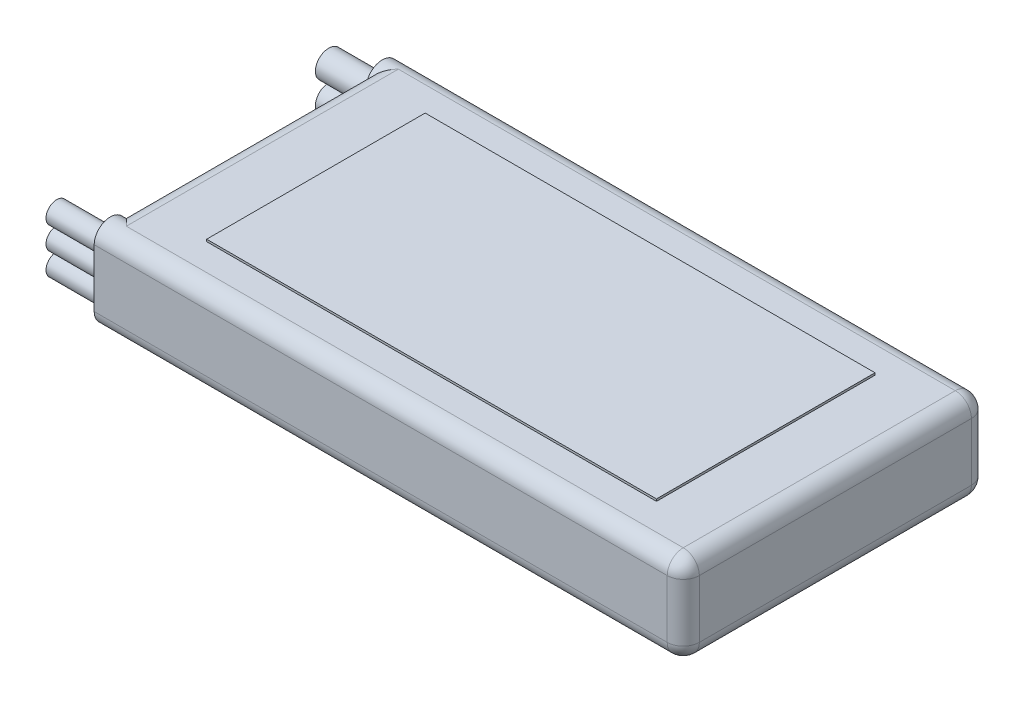
from build123d import *

# Parameters (mm, degrees)
SKETCH1_W       = 69.85
SKETCH1_H       = 36.068
BATTERY_DEPTH   = 10.668
FILLET_2_R      = 1.905
WIRE_BOSS_DEPTH = 5.08
SKETCH3_R       = 1.27
SKETCH3_R_2     = 1.5875
WIRES_2_DEPTH   = 6.35
SKETCH4_W       = 53.34
SKETCH4_H       = 25.908
LABEL_DEPTH     = 0.254


with BuildPart() as part:
    # Sketch1 → Battery (new body)
    with BuildSketch(Plane(origin=(0, 0, 0), x_dir=(1, 0, 0), z_dir=(0, 1, 0))):
        with Locations((8.399917755, 5.125761329)):
            Rectangle(SKETCH1_W, SKETCH1_H)
    extrude(amount=BATTERY_DEPTH)

    # Fillet 2
    fillet_2_edges = [part.edges().sort_by_distance(p)[0] for p in [
        (43.324917755, 10.668, -5.125761329),
        (8.399917755, 10.668, -23.159761329),
        (-26.525082245, 10.668, -5.125761329),
        (8.399917755, 0, -23.159761329),
        (43.324917755, 0, -5.125761329),
        (8.399917755, 0, 12.908238671),
        (-26.525082245, 0, -5.125761329),
        (8.399917755, 10.668, 12.908238671),
        (-26.525082245, 5.334, -23.159761329),
        (43.324917755, 5.334, -23.159761329),
        (43.324917755, 5.334, 12.908238671),
        (-26.525082245, 5.334, 12.908238671),
    ]]
    fillet(fillet_2_edges, radius=FILLET_2_R)

    # Sketch2 → Wire Boss (add)
    with BuildSketch(Plane.ZY.offset(26.525082245)):
        with BuildLine():
            Line((12.908238671, 8.763), (12.908238671, 1.905))
            ThreePointArc((12.908238671, 1.905), (11.003238671, 0), (9.098238671, 1.905))
            Line((9.098238671, 1.905), (9.098238671, 8.763))
            ThreePointArc((9.098238671, 8.763), (11.003238671, 10.668), (12.908238671, 8.763))
        make_face()
        with BuildLine():
            Line((-19.349761329, 8.763), (-19.349761329, 1.905))
            ThreePointArc((-19.349761329, 1.905), (-21.254761329, 0), (-23.159761329, 1.905))
            Line((-23.159761329, 1.905), (-23.159761329, 8.763))
            ThreePointArc((-23.159761329, 8.763), (-21.254761329, 10.668), (-19.349761329, 8.763))
        make_face()
    extrude(amount=-WIRE_BOSS_DEPTH)

    # Sketch3 → Wires 2 (add)
    with BuildSketch(Plane.ZY.offset(26.525082245)):
        with Locations((11.003238671, 8.001)):
            Circle(SKETCH3_R)
        with Locations((11.003238671, 5.334)):
            Circle(SKETCH3_R)
        with Locations((11.003238671, 2.667)):
            Circle(SKETCH3_R)
        with Locations((-21.254761329, 7.112)):
            Circle(SKETCH3_R_2)
        with Locations((-21.254761329, 3.556)):
            Circle(SKETCH3_R_2)
    extrude(amount=WIRES_2_DEPTH)

    # Sketch4 → Label (add)
    with BuildSketch(Plane(origin=(0, 10.668, 0), x_dir=(1, 0, 0), z_dir=(0, 1, 0))):
        with Locations((8.399917755, 5.125761329)):
            Rectangle(SKETCH4_W, SKETCH4_H)
    extrude(amount=LABEL_DEPTH)


solid = part.part
